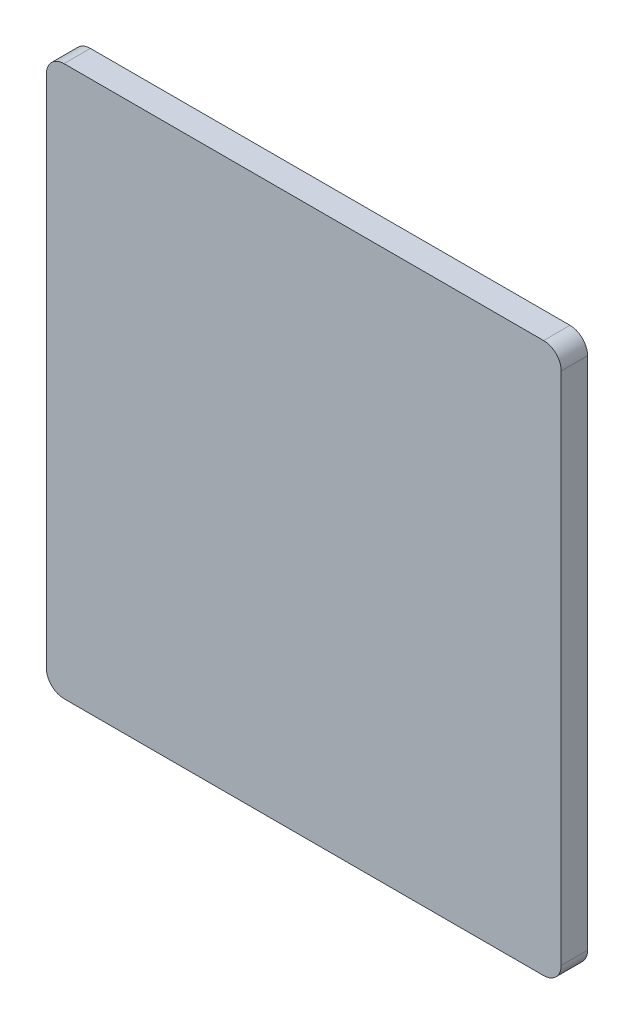
from build123d import *

# Parameters (mm, degrees)
BOSS_EXTRU_1_DEPTH = 3


with BuildPart() as part:
    # Esquisse1 → Boss.-Extru.1 (new body)
    with BuildSketch(Plane.XY):
        with BuildLine():
            Line((2, 0), (56.5, 0))
            ThreePointArc((56.5, 0), (57.914213562, 0.585786438), (58.5, 2))
            Line((58.5, 2), (58.5, 60.5))
            ThreePointArc((58.5, 60.5), (57.914213562, 61.914213562), (56.5, 62.5))
            Line((56.5, 62.5), (2, 62.5))
            ThreePointArc((2, 62.5), (0.585786438, 61.914213562), (0, 60.5))
            Line((0, 60.5), (0, 2))
            ThreePointArc((0, 2), (0.585786438, 0.585786438), (2, 0))
        make_face()
    extrude(amount=BOSS_EXTRU_1_DEPTH)


solid = part.part
